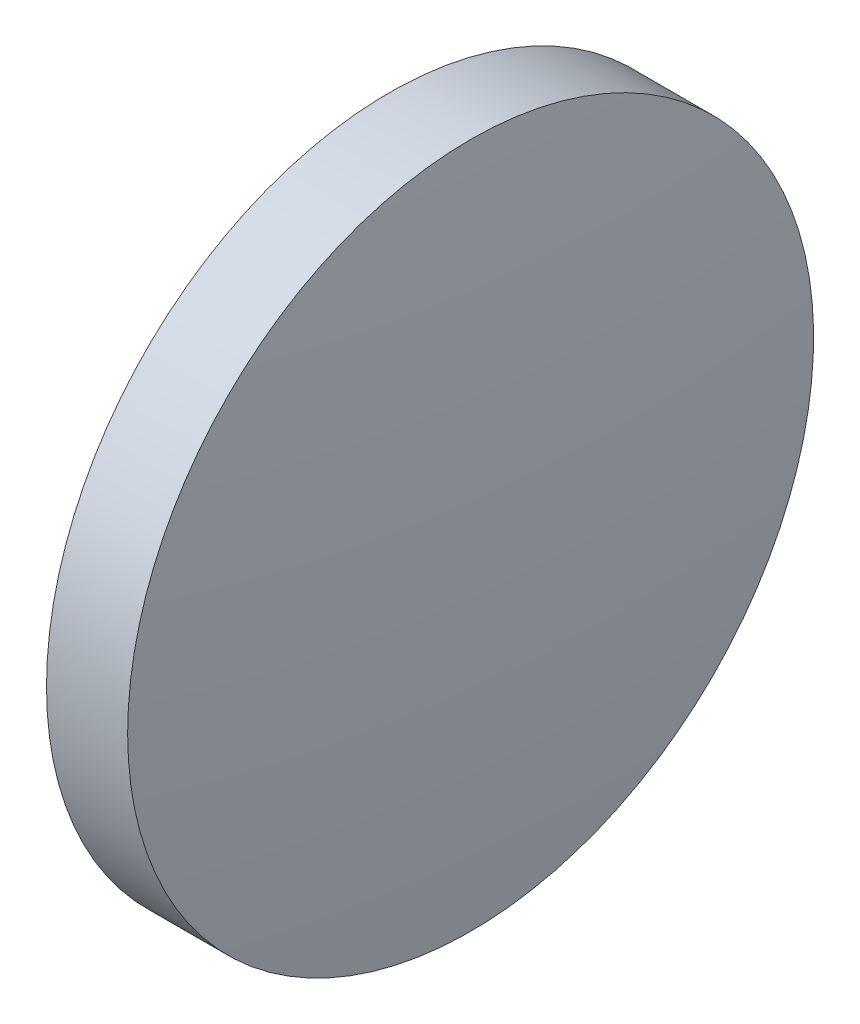
from build123d import *


with BuildPart() as part:
    # 草图1 → 旋转1 (revolve)
    with BuildSketch(Plane.XY):
        with BuildLine():
            Line((115.773606431, 65.233554926), (115.773606431, 77.933554926))
            Line((115.773606431, 77.933554926), (118.777742519, 77.933554926))
            ThreePointArc((118.777742519, 77.933554926), (119.307004382, 71.593355314), (119.483606431, 65.233554926))
            Line((119.483606431, 65.233554926), (115.773606431, 65.233554926))
        make_face()
    revolve(axis=Axis((110.165373228, 65.233554926, 0), (1, 0, 0)))


solid = part.part
